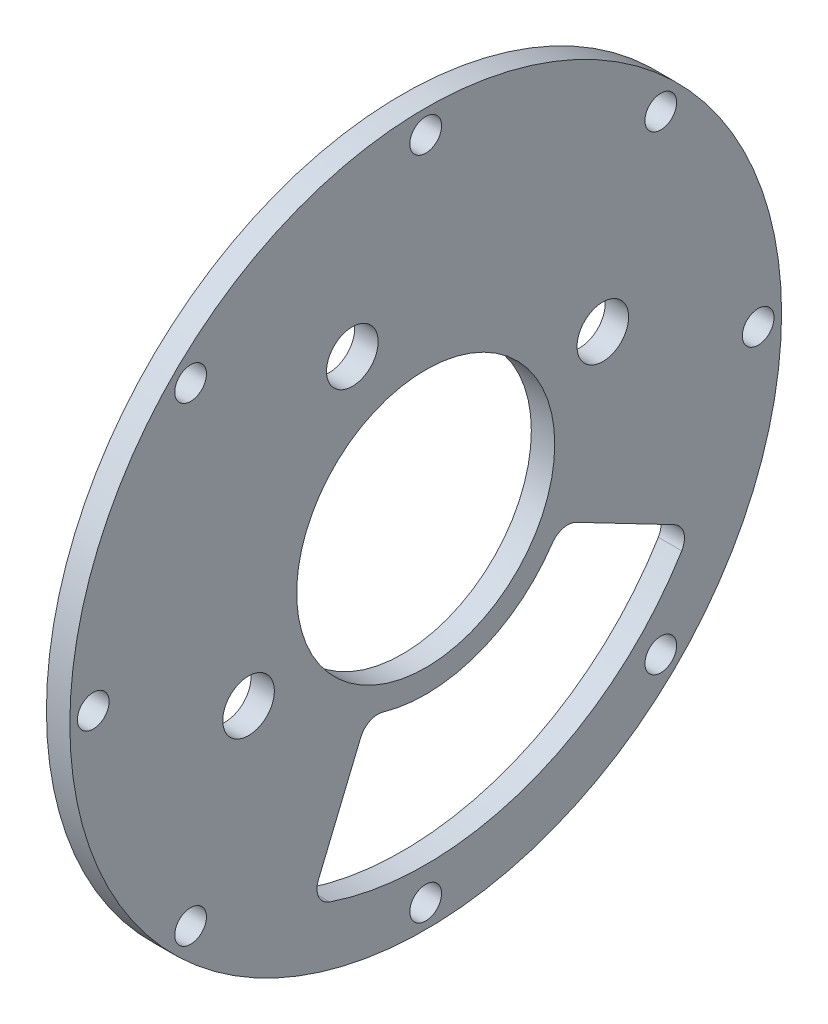
from build123d import *

# Parameters (mm, degrees)
SKETCH5_R           = 48.26
SKETCH5_R_2         = 2.15265
SKETCH5_R_3         = 3.5
SKETCH5_R_4         = 17.5
BOSS_EXTRUDE3_DEPTH = 3.175


with BuildPart() as part:
    # Sketch5 → Boss-Extrude3 (new body)
    with BuildSketch(Plane(origin=(0, 0, 0), x_dir=(0, 0, -1), z_dir=(1, 0, 0))):
        Circle(SKETCH5_R)
        with Locations((0, 45.085)):
            Circle(SKETCH5_R_2, mode=Mode.SUBTRACT)
        with Locations((-24.023795501, -9.950801949)):
            Circle(SKETCH5_R_3, mode=Mode.SUBTRACT)
        with Locations((31.87990923, 31.87990923)):
            Circle(SKETCH5_R_2, mode=Mode.SUBTRACT)
        with Locations((45.085, 0)):
            Circle(SKETCH5_R_2, mode=Mode.SUBTRACT)
        with Locations((24.018239985, 9.948012748)):
            Circle(SKETCH5_R_3, mode=Mode.SUBTRACT)
        with Locations((-9.9503853, 24.023968076)):
            Circle(SKETCH5_R_3, mode=Mode.SUBTRACT)
        with Locations((31.87990923, -31.87990923)):
            Circle(SKETCH5_R_2, mode=Mode.SUBTRACT)
        with Locations((0, -45.085)):
            Circle(SKETCH5_R_2, mode=Mode.SUBTRACT)
        with Locations((-31.87990923, -31.87990923)):
            Circle(SKETCH5_R_2, mode=Mode.SUBTRACT)
        with Locations((-45.085, 0)):
            Circle(SKETCH5_R_2, mode=Mode.SUBTRACT)
        with Locations((-31.87990923, 31.87990923)):
            Circle(SKETCH5_R_2, mode=Mode.SUBTRACT)
        Circle(SKETCH5_R_4, mode=Mode.SUBTRACT)
        with BuildLine():
            Line((20.434868218, -10.637719077), (33.719928863, -17.553483913))
            ThreePointArc((33.719928863, -17.553483913), (34.993654696, -19.123916601), (34.716893211, -21.126924191))
            ThreePointArc((34.716893211, -21.126924191), (13.899698625, -38.189108109), (-13.014558026, -38.49975168))
            ThreePointArc((-13.014558026, -38.49975168), (-14.514078084, -37.143257699), (-14.547802162, -35.121501281))
            Line((-14.547802162, -35.121501281), (-8.816223227, -21.284245682))
            ThreePointArc((-8.816223227, -21.284245682), (-7.568898247, -19.966485263), (-5.760575328, -19.817219233))
            ThreePointArc((-5.760575328, -19.817219233), (7.058440708, -19.392906461), (17.1511197, -11.478044227))
            ThreePointArc((17.1511197, -11.478044227), (18.632321778, -10.430021072), (20.434868218, -10.637719077))
        make_face(mode=Mode.SUBTRACT)
    extrude(amount=BOSS_EXTRUDE3_DEPTH)


solid = part.part
